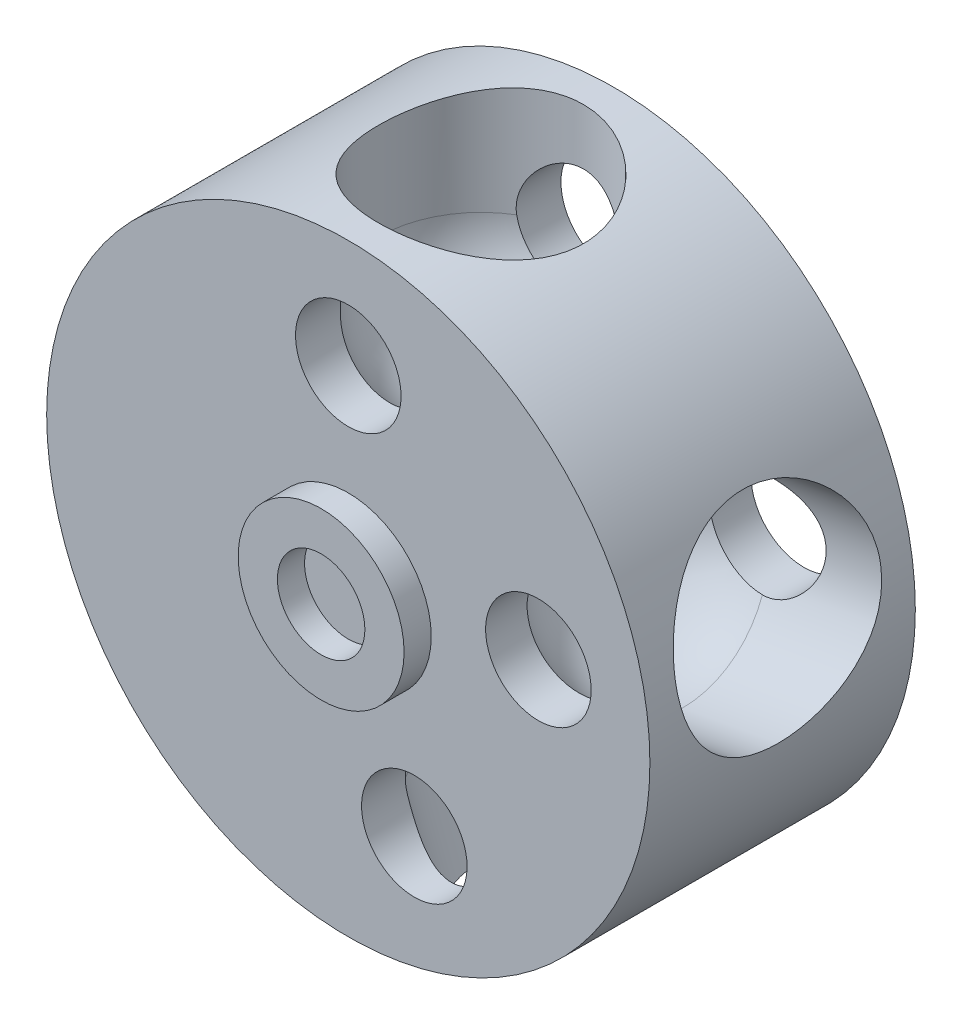
from build123d import *

# Parameters (mm, degrees)
SKETCH1_R           = 25.4
BOSS_EXTRUDE1_DEPTH = 22.352
SKETCH3_R           = 4.445
CUT_EXTRUDE1_DEPTH  = 12.1760001
CIRPATTERN1_COUNT   = 3
CIRPATTERN1_ANGLE   = 160
SKETCH4_R           = 6.985
SKETCH4_R_2         = 3.683
BOSS_EXTRUDE2_DEPTH = 2.286


with BuildPart() as part:
    # Sketch1 → Boss-Extrude1 (new body)
    with BuildSketch(Plane.XY):
        Circle(SKETCH1_R)
    extrude(amount=BOSS_EXTRUDE1_DEPTH)

    # Sketch2 → Cut-Revolve1 (revolve, cut)
    with BuildSketch(Plane(origin=(0, 0, 11.176), x_dir=(-1, 0, 0), z_dir=(0, 0, -1))):
        with BuildLine():
            Line((0, 25.4), (8.636, 25.4))
            Line((8.636, 25.4), (8.636, 15.748))
            ThreePointArc((8.636, 15.748), (6.106574162, 9.641425838), (0, 7.112))
            Line((0, 7.112), (0, 25.4))
        make_face()
    cut_revolve1 = revolve(axis=Axis((0, 0, 11.176), (0, 1, 0)), mode=Mode.SUBTRACT)

    # Sketch3 → Cut-Extrude1 (cut, symmetric)
    with BuildSketch(Plane(origin=(0, 0, 11.176), x_dir=(-1, 0, 0), z_dir=(0, 0, -1))):
        with Locations((0, 16.256)):
            Circle(SKETCH3_R)
    cut_extrude1 = extrude(amount=CUT_EXTRUDE1_DEPTH, both=True, mode=Mode.SUBTRACT)

    # CirPattern1: Cut-Revolve1, Cut-Extrude1 ×3 about axis
    cirpattern1_axis = Axis((0, 0, 0), (0, 0, -1))
    for i in range(1, CIRPATTERN1_COUNT):
        add(cut_revolve1.rotate(cirpattern1_axis, i * CIRPATTERN1_ANGLE / (CIRPATTERN1_COUNT - 1)), mode=Mode.SUBTRACT)
        add(cut_extrude1.rotate(cirpattern1_axis, i * CIRPATTERN1_ANGLE / (CIRPATTERN1_COUNT - 1)), mode=Mode.SUBTRACT)

    # Sketch4 → Boss-Extrude2 (add)
    with BuildSketch(Plane.XY.offset(22.352)):
        Circle(SKETCH4_R)
        Circle(SKETCH4_R_2, mode=Mode.SUBTRACT)
    extrude(amount=BOSS_EXTRUDE2_DEPTH)


solid = part.part
